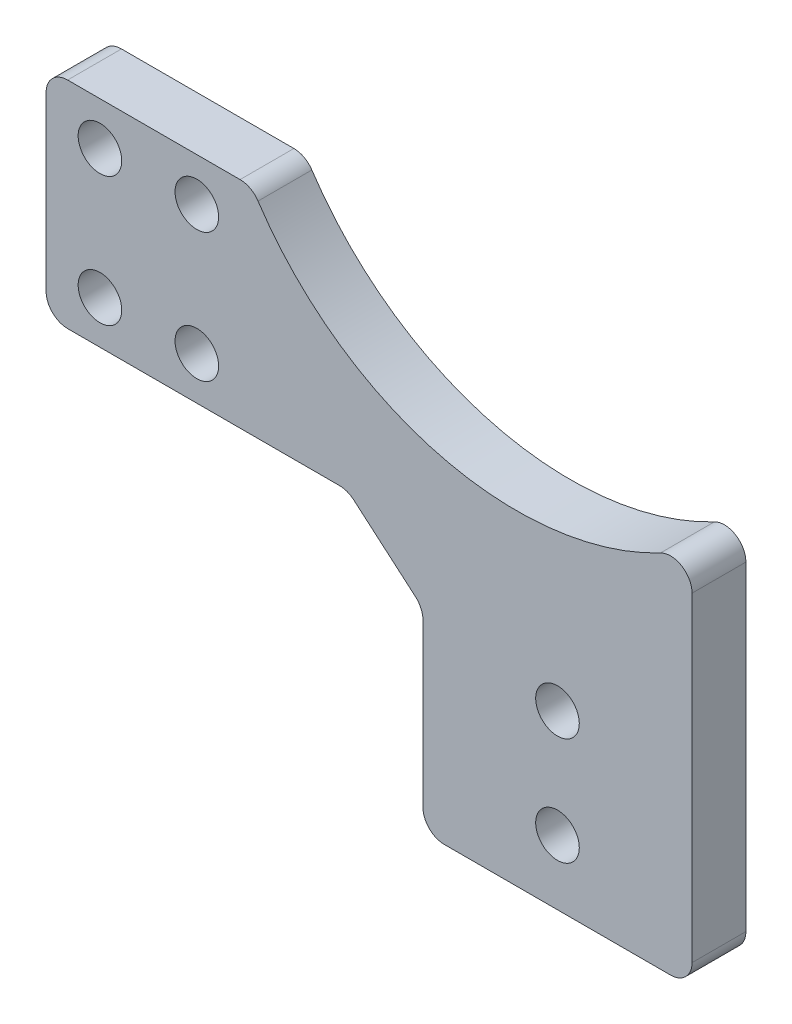
from build123d import *

# Parameters (mm, degrees)
EXTRUDE_1_DEPTH          = 2.5
FILLET_1_R               = 2
FILLET_2_R               = 2
SKETCH_2_R               = 2.025
CUT_EXTRUDE_1_DEPTH      = 6
SKETCH_3_W               = 25
SKETCH_3_H               = 6
CUT_EXTRUDE_2_DEPTH      = 6
FILLET_3_R               = 2
SKETCH_4_R               = 2.025
CUT_EXTRUDE_3_DEPTH      = 1
CUT_EXTRUDE_3_DEPTH_BACK = 6
SKETCH_5_R               = 2.025
CUT_EXTRUDE_4_DEPTH      = 1
CUT_EXTRUDE_4_DEPTH_BACK = 6


with BuildPart() as part:
    # 草图1 → 凸台-拉伸1 (new body, symmetric)
    with BuildSketch(Plane.XY):
        with BuildLine():
            Line((0, 0), (0, -24))
            Line((0, -24), (25, -24))
            Line((25, -24), (25, 17.256579859))
            ThreePointArc((25, 17.256579859), (2.677238779, 12.836790892), (-15.885361498, 26))
            Line((-15.885361498, 26), (-35, 26))
            Line((-35, 26), (-35, 6))
            Line((-35, 6), (-7, 6))
            Line((-7, 6), (0, 0))
        make_face()
    extrude(amount=EXTRUDE_1_DEPTH, both=True)

    # 圆角1
    fillet_1_edges = [part.edges().sort_by_distance(p)[0] for p in [
        (-7, 6, 0),
        (-35, 6, 0),
        (-35, 26, 0),
        (25, -24, 0),
        (0, -24, 0),
        (0, 0, 0),
    ]]
    fillet(fillet_1_edges, radius=FILLET_1_R)

    # 圆角2
    fillet_2_edges = [part.edges().sort_by_distance(p)[0] for p in [
        (-15.885361498, 26, 0),
        (25, 17.256579859, 0),
    ]]
    fillet(fillet_2_edges, radius=FILLET_2_R)

    # 草图2 → 切除-拉伸1 (cut, through all)
    with BuildSketch(Plane.XY.offset(2.5)):
        with Locations((12.5, -2)):
            Circle(SKETCH_2_R)
        with Locations((12.5, -12)):
            Circle(SKETCH_2_R)
    extrude(amount=-CUT_EXTRUDE_1_DEPTH, mode=Mode.SUBTRACT)

    # 草图3 → 切除-拉伸2 (cut, through all)
    with BuildSketch(Plane.XY.offset(2.5)):
        with Locations((12.5, -21)):
            Rectangle(SKETCH_3_W, SKETCH_3_H)
    extrude(amount=-CUT_EXTRUDE_2_DEPTH, mode=Mode.SUBTRACT)

    # 圆角3
    fillet_3_edges = [part.edges().sort_by_distance(p)[0] for p in [
        (0, -18, 0),
        (25, -18, 0),
    ]]
    fillet(fillet_3_edges, radius=FILLET_3_R)

    # 草图4 → 切除-拉伸3 (cut, two sides)
    with BuildSketch(Plane.XY.offset(2.5)) as cut_extrude_3_sk:
        with Locations((-30, 22)):
            Circle(SKETCH_4_R)
        with Locations((-30, 10)):
            Circle(SKETCH_4_R)
    extrude(amount=CUT_EXTRUDE_3_DEPTH, mode=Mode.SUBTRACT)
    extrude(cut_extrude_3_sk.sketch, amount=-CUT_EXTRUDE_3_DEPTH_BACK, mode=Mode.SUBTRACT)

    # 草图5 → 切除-拉伸4 (cut, two sides)
    with BuildSketch(Plane.XY.offset(2.5)) as cut_extrude_4_sk:
        with Locations((-21, 10)):
            Circle(SKETCH_5_R)
        with Locations((-21, 22)):
            Circle(SKETCH_5_R)
    extrude(amount=CUT_EXTRUDE_4_DEPTH, mode=Mode.SUBTRACT)
    extrude(cut_extrude_4_sk.sketch, amount=-CUT_EXTRUDE_4_DEPTH_BACK, mode=Mode.SUBTRACT)


solid = part.part
